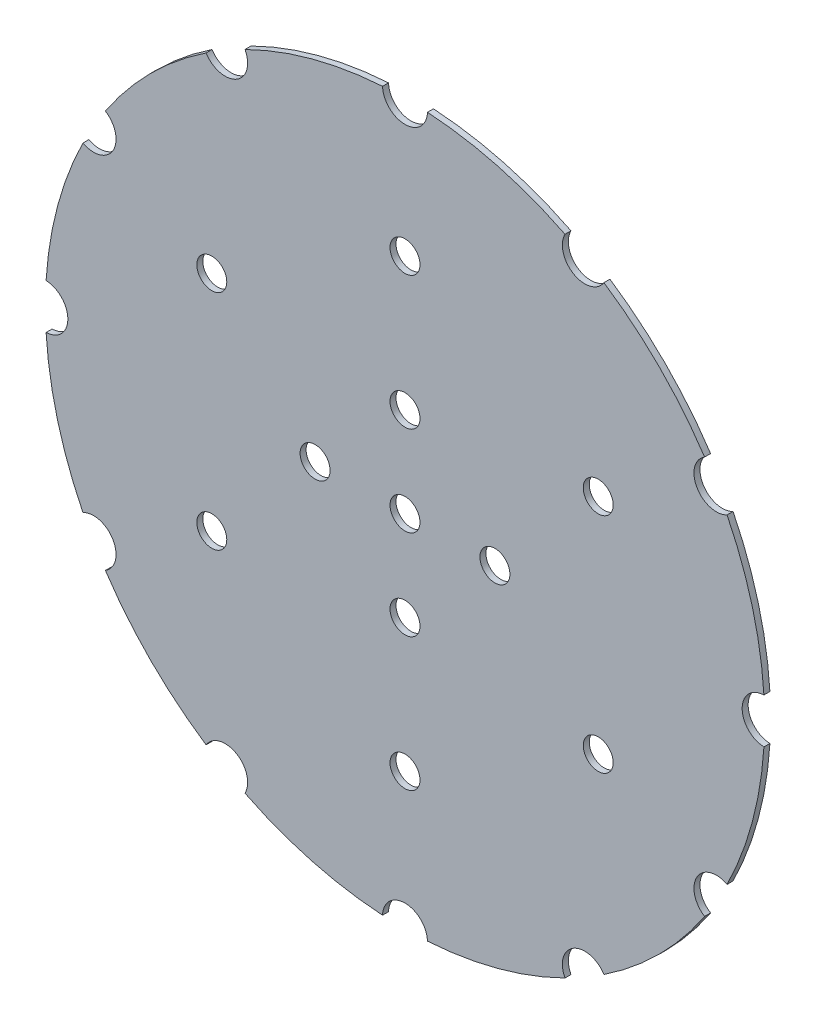
from build123d import *

# Parameters (mm, degrees)
SKETCH1_R           = 152.4
BOSS_EXTRUDE1_DEPTH = 2.54
SKETCH2_R           = 9.525
SKETCH2_R_2         = 6.35
CUT_EXTRUDE2_DEPTH  = 3.54
SKETCH4_R           = 6.35
CUT_EXTRUDE4_DEPTH  = 2.54


with BuildPart() as part:
    # Sketch1 → Boss-Extrude1 (new body)
    with BuildSketch(Plane.XY):
        Circle(SKETCH1_R)
    extrude(amount=BOSS_EXTRUDE1_DEPTH)

    # Sketch2 → Cut-Extrude2 (cut, through all)
    with BuildSketch(Plane.XY):
        with Locations((152.4, 0)):
            Circle(SKETCH2_R)
        with Locations((131.982271537, -76.2)):
            Circle(SKETCH2_R)
        with Locations((76.2, -131.982271537)):
            Circle(SKETCH2_R)
        with Locations((0, -152.4)):
            Circle(SKETCH2_R)
        with Locations((-76.2, -131.982271537)):
            Circle(SKETCH2_R)
        with Locations((-131.982271537, -76.2)):
            Circle(SKETCH2_R)
        with Locations((-152.4, 0)):
            Circle(SKETCH2_R)
        with Locations((-131.982271537, 76.2)):
            Circle(SKETCH2_R)
        with Locations((-76.2, 131.982271537)):
            Circle(SKETCH2_R)
        with Locations((0, 152.4)):
            Circle(SKETCH2_R)
        with Locations((76.2, 131.982271537)):
            Circle(SKETCH2_R)
        with Locations((131.982271537, 76.2)):
            Circle(SKETCH2_R)
        with Locations((38.1, 0)):
            Circle(SKETCH2_R_2)
        with Locations((0, -38.1)):
            Circle(SKETCH2_R_2)
        with Locations((-38.1, 0)):
            Circle(SKETCH2_R_2)
        with Locations((0, 38.1)):
            Circle(SKETCH2_R_2)
        with Locations((81.879271907, -47.273019677)):
            Circle(SKETCH2_R_2)
        with Locations((0, -94.546039353)):
            Circle(SKETCH2_R_2)
        with Locations((-81.879271907, -47.273019677)):
            Circle(SKETCH2_R_2)
        with Locations((-81.879271907, 47.273019677)):
            Circle(SKETCH2_R_2)
        with Locations((0, 94.546039353)):
            Circle(SKETCH2_R_2)
        with Locations((81.879271907, 47.273019677)):
            Circle(SKETCH2_R_2)
    extrude(amount=CUT_EXTRUDE2_DEPTH, mode=Mode.SUBTRACT)

    # Sketch4 → Cut-Extrude4 (cut)
    with BuildSketch(Plane.XY):
        Circle(SKETCH4_R)
    extrude(amount=CUT_EXTRUDE4_DEPTH, mode=Mode.SUBTRACT)


solid = part.part
